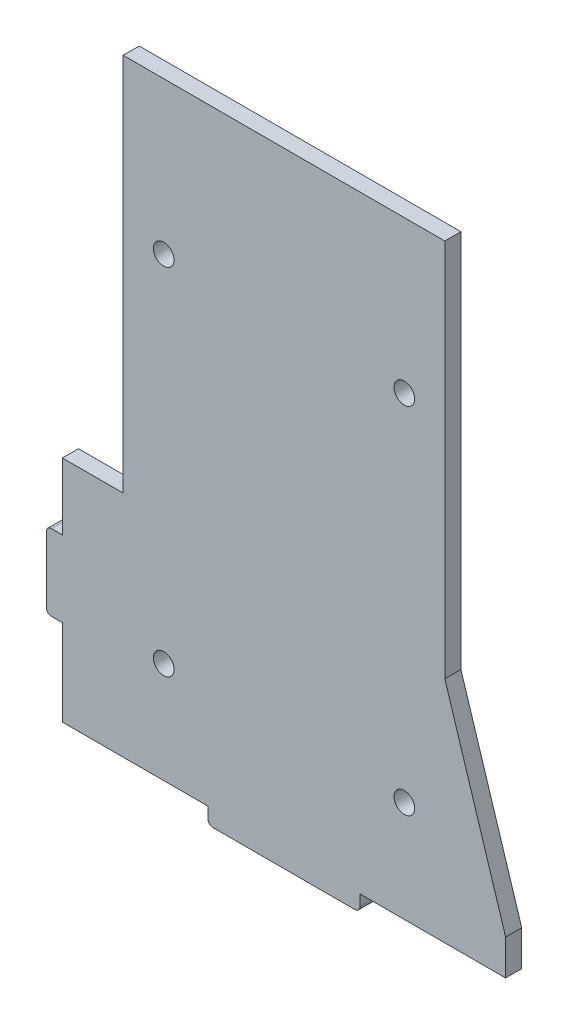
from build123d import *

# Parameters (mm, degrees)
BOSS_EXTRUDE1_DEPTH = 3.175
SKETCH2_R           = 2.05
CUT_EXTRUDE1_DEPTH  = 4.175
SKETCH3_W           = 3.175
SKETCH3_H           = 15
BOSS_EXTRUDE2_DEPTH = 3.175
FILLET1_R           = 1


with BuildPart() as part:
    # Sketch1 → Boss-Extrude1 (new body)
    with BuildSketch(Plane.XY):
        Polygon((-31.75, -60), (-15, -60), (-15, -63.175), (15, -63.175), (15, -60), (31.75, -60), (43.75, -60), (43.75, -53), (31.75, -14.842431943), (31.75, 60), (-31.75, 60), (-31.75, -14.842431943), (-43.75, -14.842431943), (-43.75, -53), (-43.75, -60), align=None)
    extrude(amount=BOSS_EXTRUDE1_DEPTH)

    # Sketch2 → Cut-Extrude1 (cut, through all)
    with BuildSketch(Plane.XY.offset(3.175)):
        with Locations((23.75, 30)):
            Circle(SKETCH2_R)
        with Locations((23.75, -40)):
            Circle(SKETCH2_R)
        with Locations((-23.75, -40)):
            Circle(SKETCH2_R)
        with Locations((-23.75, 30)):
            Circle(SKETCH2_R)
    extrude(amount=-CUT_EXTRUDE1_DEPTH, mode=Mode.SUBTRACT)

    # Sketch3 → Boss-Extrude2 (add)
    with BuildSketch(Plane.ZY.offset(43.75)):
        with Locations((1.5875, -35.5)):
            Rectangle(SKETCH3_W, SKETCH3_H)
    extrude(amount=BOSS_EXTRUDE2_DEPTH)

    # Fillet1
    fillet1_edges = [part.edges().sort_by_distance(p)[0] for p in [
        (15, -63.175, 1.5875),
        (-15, -63.175, 1.5875),
        (-46.925, -43, 1.5875),
        (-46.925, -28, 1.5875),
    ]]
    fillet(fillet1_edges, radius=FILLET1_R)


solid = part.part
